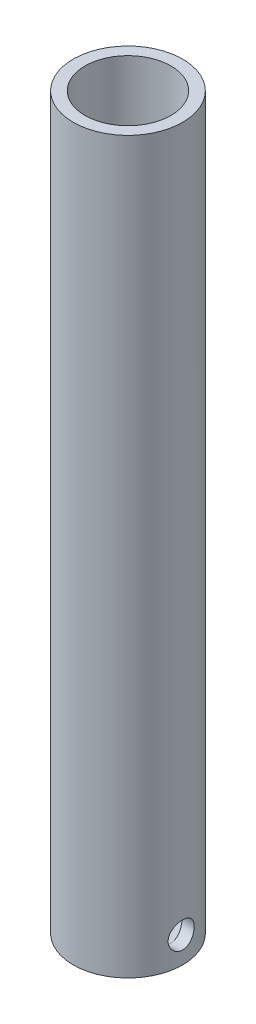
from build123d import *

# Parameters (mm, degrees)
SKETCH1_R           = 13.335
SKETCH1_R_2         = 10.4648
BOSS_EXTRUDE1_DEPTH = 177.8
SKETCH1_2_R         = 10.4648
BOSS_EXTRUDE2_DEPTH = 3.175
SKETCH3_R           = 3.175
CUT_EXTRUDE1_DEPTH  = 14.351


with BuildPart() as part:
    # Sketch1 → Boss-Extrude1 (new body)
    with BuildSketch(Plane(origin=(0, 0, 0), x_dir=(1, 0, 0), z_dir=(0, 1, 0))):
        Circle(SKETCH1_R)
        Circle(SKETCH1_R_2, mode=Mode.SUBTRACT)
    extrude(amount=BOSS_EXTRUDE1_DEPTH)

    # Sketch1_2 → Boss-Extrude2 (add)
    with BuildSketch(Plane(origin=(0, 0, 0), x_dir=(1, 0, 0), z_dir=(0, 1, 0))):
        Circle(SKETCH1_2_R)
    extrude(amount=BOSS_EXTRUDE2_DEPTH)

    # Sketch3 → Cut-Extrude1 (cut)
    with BuildSketch(Plane(origin=(13.335, 0, 0), x_dir=(0, 0, -1), z_dir=(1, 0, 0))):
        with Locations((0, 6.35)):
            Circle(SKETCH3_R)
    extrude(amount=-CUT_EXTRUDE1_DEPTH, mode=Mode.SUBTRACT)


solid = part.part
